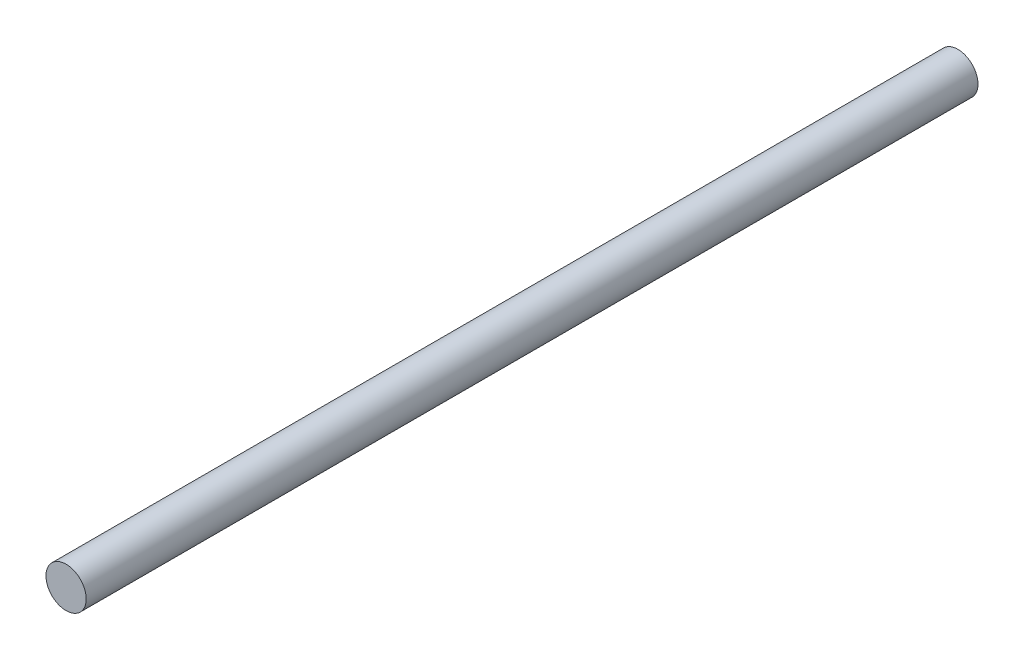
from build123d import *

# Parameters (mm, degrees)
SKETCH1_R           = 7.9
BOSS_EXTRUDE1_DEPTH = 350


with BuildPart() as part:
    # Sketch1 → Boss-Extrude1 (new body)
    with BuildSketch(Plane.XY):
        Circle(SKETCH1_R)
    extrude(amount=BOSS_EXTRUDE1_DEPTH)


solid = part.part
